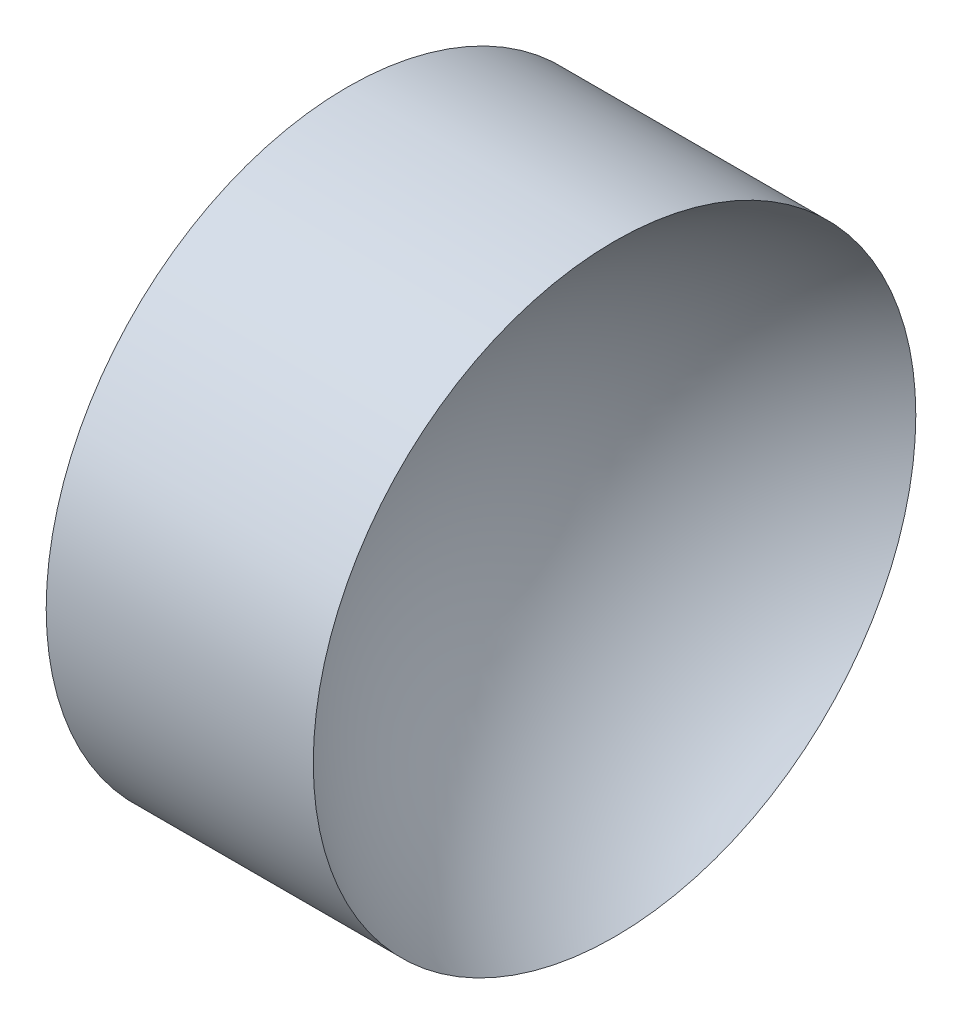
from build123d import *


with BuildPart() as part:
    # 草图1 → 旋转1 (revolve)
    with BuildSketch(Plane.XY, mode=Mode.PRIVATE) as revolve_1_sk:
        with BuildLine():
            Line((41.365827325, 26.062252183), (41.365827325, 31.062252183))
            Line((41.365827325, 31.062252183), (45.798307074, 31.062252183))
            ThreePointArc((45.798307074, 31.062252183), (43.653880348, 28.96019684), (42.86703893, 26.062252183))
            Line((42.86703893, 26.062252183), (41.365827325, 26.062252183))
        make_face()
    revolve(revolve_1_sk.sketch.rotate(Axis((39.736500013, 26.062252183, 0), (1, 0, 0)), 180), axis=Axis((39.736500013, 26.062252183, 0), (1, 0, 0)))  # turned: the seam where the file's is


solid = part.part
